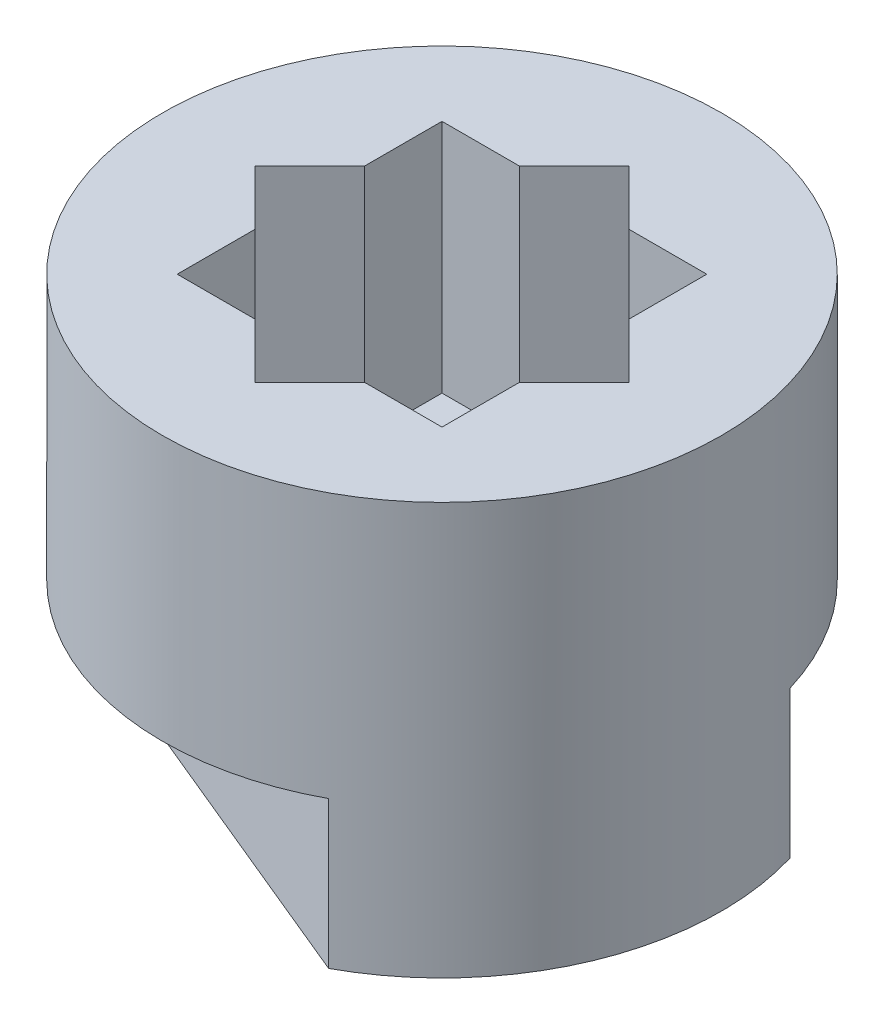
from build123d import *

# Parameters (mm, degrees)
SKETCH_1_R          = 4.75
EXTRUDE_1_DEPTH     = 7
CUT_EXTRUDE_1_DEPTH = 4
SKETCH_3_R          = 1.85
CUT_EXTRUDE_2_DEPTH = 8
CUT_EXTRUDE_7_DEPTH = 2.5


with BuildPart() as part:
    # Эскиз1 → Бобышка-Вытянуть1 (new body)
    with BuildSketch(Plane(origin=(0, 0, 0), x_dir=(1, 0, 0), z_dir=(0, 1, 0))):
        Circle(SKETCH_1_R)
    extrude(amount=EXTRUDE_1_DEPTH)

    # Эскиз2 → Вырез-Вытянуть1 (cut)
    with BuildSketch(Plane(origin=(0, 7, 0), x_dir=(1, 0, 0), z_dir=(0, 1, 0))):
        Polygon((-3.181980515, 0), (-2.25, -0.931980515), (-2.25, -2.25), (-0.931980515, -2.25), (0, -3.181980515), (0.931980515, -2.25), (2.25, -2.25), (2.25, -0.931980515), (3.181980515, 0), (2.25, 0.931980515), (2.25, 2.25), (0.931980515, 2.25), (0, 3.181980515), (-0.931980515, 2.25), (-2.25, 2.25), (-2.25, 0.931980515), align=None)
    extrude(amount=-CUT_EXTRUDE_1_DEPTH, mode=Mode.SUBTRACT)

    # Эскиз3 → Вырез-Вытянуть2 (cut, through all)
    with BuildSketch(Plane.XZ):
        Circle(SKETCH_3_R)
    extrude(amount=-CUT_EXTRUDE_2_DEPTH, mode=Mode.SUBTRACT)

    # Эскиз4<3> → Вырез-Вытянуть7 (cut)
    with BuildSketch(Plane.XZ):
        with BuildLine():
            ThreePointArc((2.254348542, 4.180958341), (-1.817746304, 4.388427779), (-4.550449136, 1.362318854))
            Line((-4.550449136, 1.362318854), (2.254348542, 4.180958341))
        make_face()
        with BuildLine():
            Line((4.550449136, -1.362318854), (-2.254348542, -4.180958341))
            ThreePointArc((-2.254348542, -4.180958341), (1.817746304, -4.388427779), (4.550449136, -1.362318854))
        make_face()
    extrude(amount=-CUT_EXTRUDE_7_DEPTH, mode=Mode.SUBTRACT)


solid = part.part
